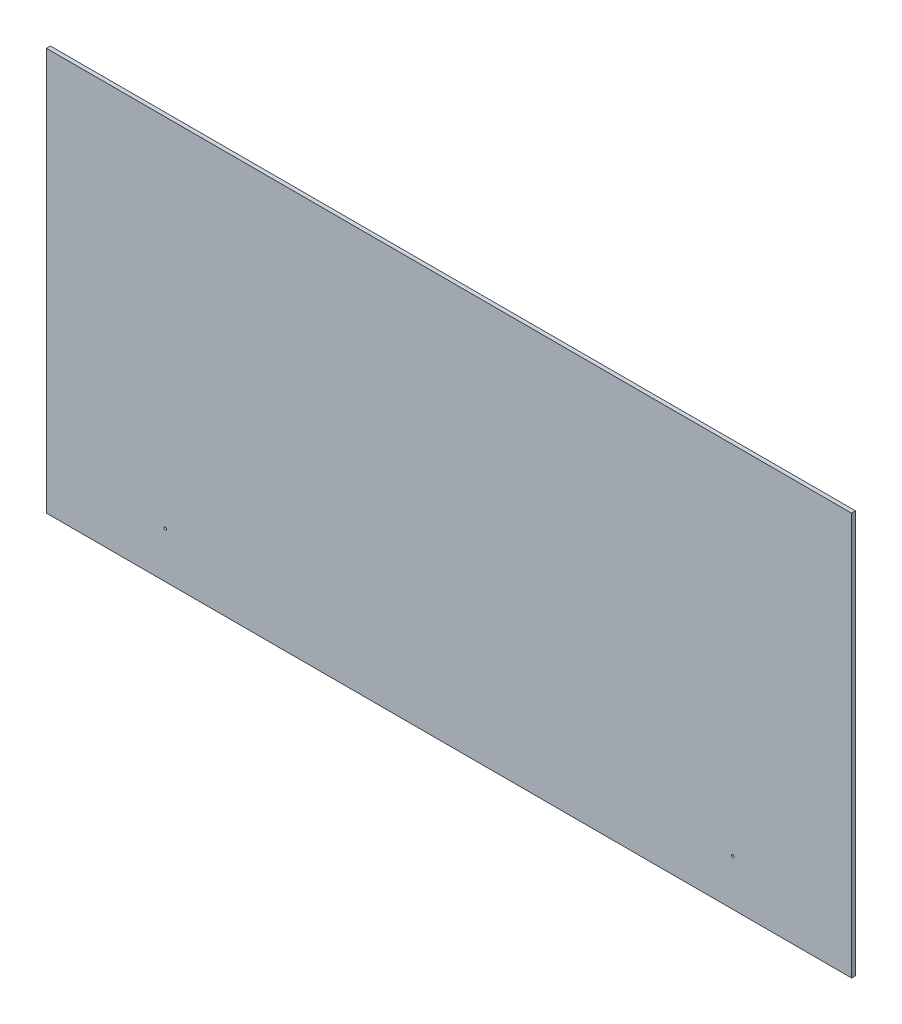
from build123d import *

# Parameters (mm, degrees)
ESQUISSE1_W             = 1220
ESQUISSE1_H             = 610
BOSS_EXTRU_1_DEPTH      = 6
ESQUISSE2_R             = 2
ENL_V_MAT_EXTRU_1_DEPTH = 6


with BuildPart() as part:
    # Esquisse1 → Boss.-Extru.1 (new body)
    with BuildSketch(Plane.XY):
        with Locations((-610, 305)):
            Rectangle(ESQUISSE1_W, ESQUISSE1_H)
    extrude(amount=BOSS_EXTRU_1_DEPTH)

    # Esquisse2 → Enlèv. mat.-Extru.1 (cut)
    with BuildSketch(Plane.XY.offset(6)):
        with Locations((-1040, 70)):
            Circle(ESQUISSE2_R)
        with Locations((-180, 70)):
            Circle(ESQUISSE2_R)
    extrude(amount=-ENL_V_MAT_EXTRU_1_DEPTH, mode=Mode.SUBTRACT)


solid = part.part
